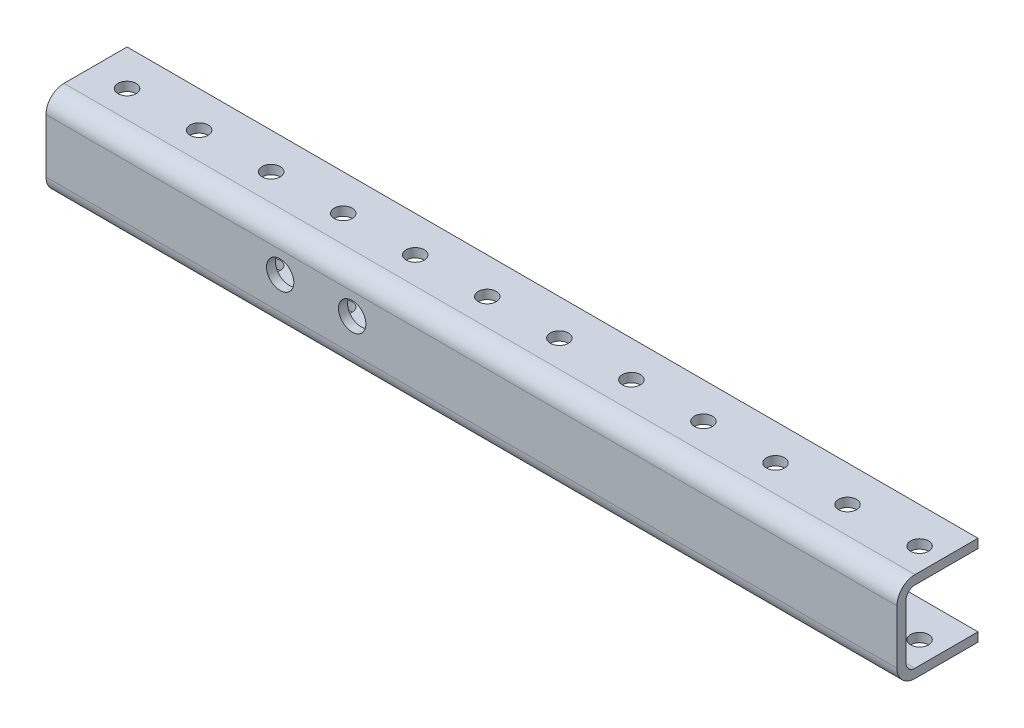
from build123d import *

# Parameters (mm, degrees)
SKETCH1_W          = 889
SKETCH1_H          = 31.75
EXTRUDE1_DEPTH     = 28.575
EXTRUDE2_REACH     = 891.702
SKETCH2_W          = 25.4
SKETCH2_H          = 25.4
HOLE1_D            = 6.35
HOLE1_DEPTH        = 3.175
LPATTERN1_COUNT    = 35
LPATTERN1_PITCH    = 25.4
HOLE2_D            = 9.652
LPATTERN2_COUNT    = 12
LPATTERN2_PITCH    = 25.4
HOLE3_D            = 9.652
HOLE4_D            = 9.652
LPATTERN3_COUNT    = 12
LPATTERN3_PITCH    = 25.4
HOLE5_D            = 3.175
HOLE6_D            = 6.35
LPATTERN4_COUNT    = 35
LPATTERN4_PITCH    = 25.4
FILLET1_R          = 3.175
FILLET2_R          = 3.175
FILLET3_R          = 6.35
FILLET4_R          = 6.35
SKETCH15_W         = 596.207849475
SKETCH15_H         = 40.608240695
CUT_EXTRUDE1_DEPTH = 77


with BuildPart() as part:
    # Sketch1 → Extrude1 (new body)
    with BuildSketch(Plane.XY.offset(3.175)):
        with Locations((428.480011997, 8.672957166)):
            Rectangle(SKETCH1_W, SKETCH1_H)
    extrude(amount=-EXTRUDE1_DEPTH)

    # Sketch2 → Extrude2 (cut, up to next)
    with BuildSketch(Plane.ZY.offset(16.019988003), mode=Mode.PRIVATE) as extrude2_sk1:
        with Locations((-12.7, 8.672957166)):
            Rectangle(SKETCH2_W, SKETCH2_H)
    extrude2_tool1 = extrude(extrude2_sk1.sketch, amount=-EXTRUDE2_REACH, mode=Mode.PRIVATE) & part.part
    add(extrude2_tool1.solids().sort_by_distance((-16.019988, 8.672957, -12.7))[0], mode=Mode.SUBTRACT)

    # Hole1
    with Locations(Plane(origin=(0, 24.547957166, 0), x_dir=(-1, 0, 0), z_dir=(0, 1, 0))):
        with Locations((3.319988003, -12.7)):
            hole1 = Hole(HOLE1_D / 2, depth=HOLE1_DEPTH)

    # LPattern1: Hole1 ×35
    with Locations(*[(i * LPATTERN1_PITCH, 0, 0) for i in range(1, LPATTERN1_COUNT)]):
        add(hole1, mode=Mode.SUBTRACT)

    # Hole2 (through all)
    with Locations(Plane.XY.offset(3.175)):
        with Locations((66.530011997, 10.577957166)):
            hole2 = Hole(HOLE2_D / 2)

    # LPattern2: Hole2 ×12, 8 skipped
    with Locations(*[(i * LPATTERN2_PITCH, 0, 0) for i in range(1, LPATTERN2_COUNT) if i not in (2, 3, 4, 5, 6, 7, 8, 9)]):
        add(hole2, mode=Mode.SUBTRACT)

    # Hole3 (through all)
    with Locations(Plane.XY.offset(3.175)):
        with Locations((428.480011997, 6.767957166)):
            Hole(HOLE3_D / 2)

    # Hole4 (through all)
    with Locations(Plane.XY.offset(3.175)):
        with Locations((511.030011997, 10.577957166)):
            hole4 = Hole(HOLE4_D / 2)

    # LPattern3: Hole4 ×12, 8 skipped
    with Locations(*[(i * LPATTERN3_PITCH, 0, 0) for i in range(1, LPATTERN3_COUNT) if i not in (2, 3, 4, 5, 6, 7, 8, 9)]):
        add(hole4, mode=Mode.SUBTRACT)

    # Hole5 (through all)
    with Locations(Plane.XY.offset(3.175)):
        with Locations((669.780011997, 8.672957166)):
            Hole(HOLE5_D / 2)

    # Hole6 (through all)
    with Locations(Plane(origin=(0, -4.027042834, 0), x_dir=(-1, 0, 0), z_dir=(0, 1, 0))):
        with Locations((3.319988003, -12.7)):
            hole6 = Hole(HOLE6_D / 2)

    # LPattern4: Hole6 ×35
    with Locations(*[(i * LPATTERN4_PITCH, 0, 0) for i in range(1, LPATTERN4_COUNT)]):
        add(hole6, mode=Mode.SUBTRACT)

    # Fillet1
    fillet1_edges = [part.edges().sort_by_distance(p)[0] for p in [
        (428.480011997, 21.372957166, 0),
    ]]
    fillet(fillet1_edges, radius=FILLET1_R)

    # Fillet2
    fillet2_edges = [part.edges().sort_by_distance(p)[0] for p in [
        (428.480011997, -4.027042834, 0),
    ]]
    fillet(fillet2_edges, radius=FILLET2_R)

    # Fillet3
    fillet3_edges = [part.edges().sort_by_distance(p)[0] for p in [
        (428.480011997, -7.202042834, 3.175),
    ]]
    fillet(fillet3_edges, radius=FILLET3_R)

    # Fillet4
    fillet4_edges = [part.edges().sort_by_distance(p)[0] for p in [
        (428.480011997, 24.547957166, 3.175),
    ]]
    fillet(fillet4_edges, radius=FILLET4_R)

    # Sketch15 → Cut-Extrude1 (cut)
    with BuildSketch(Plane(origin=(0, 24.547957166, 0), x_dir=(1, 0, 0), z_dir=(0, 1, 0))):
        with Locations((582.083936734, 5.095879653)):
            Rectangle(SKETCH15_W, SKETCH15_H)
    extrude(amount=-CUT_EXTRUDE1_DEPTH, mode=Mode.SUBTRACT)


solid = part.part
